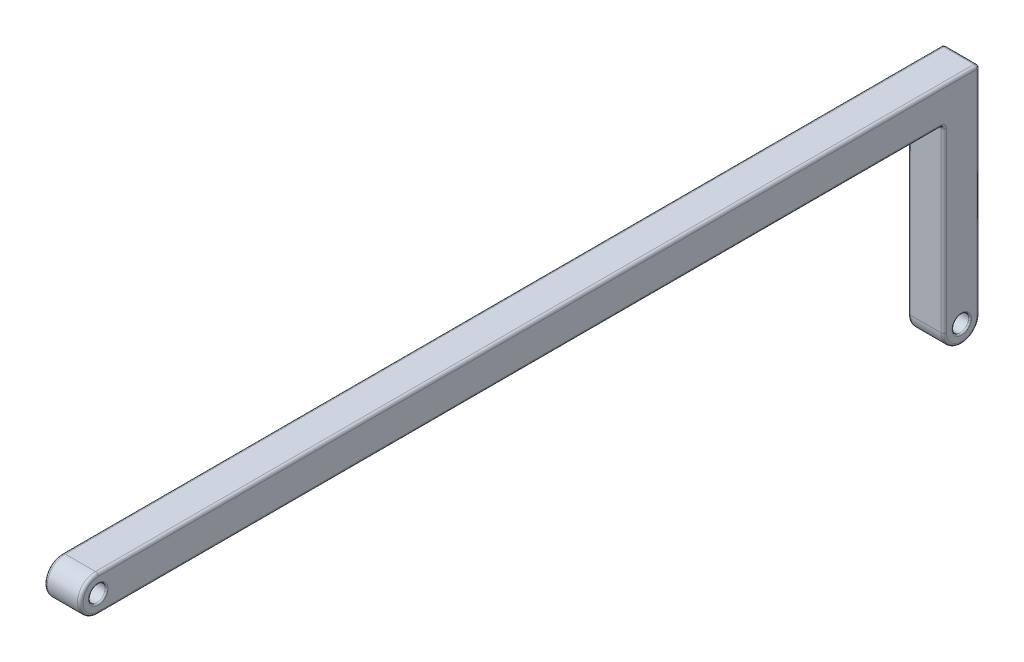
from build123d import *

# Parameters (mm, degrees)
SKETCH1_R           = 0.575
BOSS_EXTRUDE1_DEPTH = 2.5
FILLET2_R           = 0.1
FILLET3_R           = 0.2


with BuildPart() as part:
    # Sketch1 → Boss-Extrude1 (new body)
    with BuildSketch(Plane(origin=(0, 0, 0), x_dir=(0, 0, -1), z_dir=(1, 0, 0))):
        with BuildLine():
            Line((0, 0), (60, 0))
            Line((60, 0), (61.25, 0))
            Line((61.25, 0), (61.25, -15))
            ThreePointArc((61.25, -15), (60, -16.25), (58.75, -15))
            Line((58.75, -15), (58.75, -2.5))
            Line((58.75, -2.5), (0, -2.5))
            ThreePointArc((0, -2.5), (-1.25, -1.25), (0, 0))
        make_face()
        with Locations((0, -1.25)):
            Circle(SKETCH1_R, mode=Mode.SUBTRACT)
        with Locations((60, -15)):
            Circle(SKETCH1_R, mode=Mode.SUBTRACT)
    extrude(amount=BOSS_EXTRUDE1_DEPTH)

    # Fillet2
    fillet2_edges = [part.edges().sort_by_distance(p)[0] for p in [
        (0, -1.25, 0.575),
        (2.5, -1.25, 0.575),
        (0, -15, -59.425),
        (2.5, -15, -59.425),
    ]]
    fillet(fillet2_edges, radius=FILLET2_R)

    # Fillet3
    fillet3_edges = [part.edges().sort_by_distance(p)[0] for p in [
        (0, -1.25, 1.25),
        (1.25, 0, -61.25),
        (2.5, -8.75, -58.75),
        (1.25, -2.5, -58.75),
        (2.5, -16.25, -60),
        (2.5, -7.5, -61.25),
        (2.5, 0, -30.625),
        (2.5, -1.25, 1.25),
        (0, 0, -30.625),
        (0, -7.5, -61.25),
        (0, -16.25, -60),
        (2.5, -2.5, -29.375),
        (0, -8.75, -58.75),
        (0, -2.5, -29.375),
    ]]
    fillet(fillet3_edges, radius=FILLET3_R)


solid = part.part
